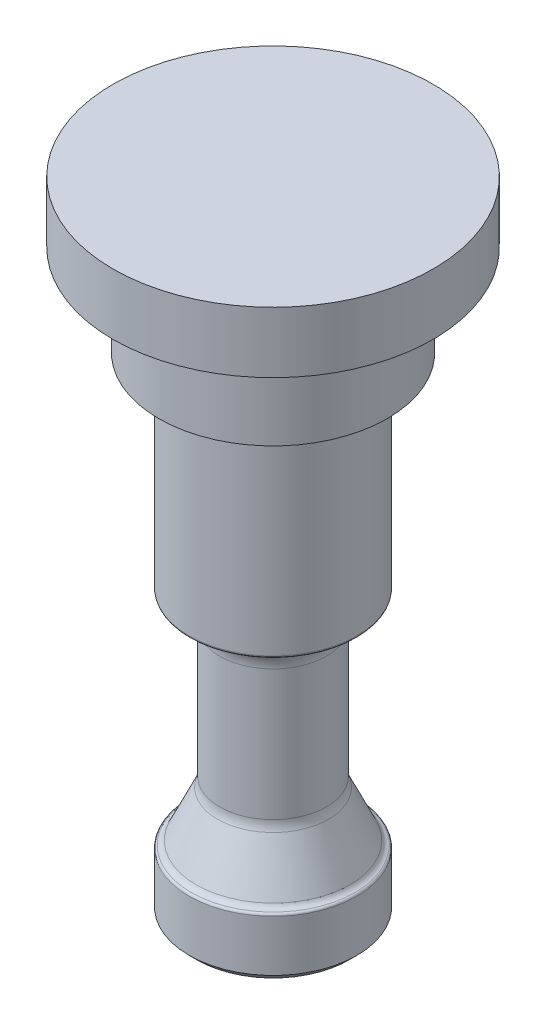
from build123d import *

# Parameters (mm, degrees)
SKETCH1_R               = 8.73125
MAIN_DEPTH              = 50.8
CHAMFER1_SIZE           = 0.79375
FILLET1_R               = 0.254
SKETCH6_R               = 11.90625
SPRING_STABILIZER_DEPTH = 9.525
SKETCH3_R               = 16.66875
TOP_CAP_DEPTH           = 6.35
FILLET2_R               = 1.27
SKETCH7_R               = 2.38125
CUT_EXTRUDE1_DEPTH      = 19.05


with BuildPart() as part:
    # Sketch1 → main (new body)
    with BuildSketch(Plane(origin=(0, 0, 0), x_dir=(1, 0, 0), z_dir=(0, 1, 0))):
        with Locations(Location((0, 0, 0), (0, 0, 270))):
            Circle(SKETCH1_R)
    extrude(amount=MAIN_DEPTH)

    # Chamfer1
    chamfer1_edges = [part.edges().sort_by_distance(p)[0] for p in [
        (0, 0, -8.73125),
    ]]
    chamfer(chamfer1_edges, length=CHAMFER1_SIZE)

    # Sketch2 → ball_channel (revolve, cut)
    with BuildSketch(Plane(origin=(0, 0, 0), x_dir=(0, 0, -1), z_dir=(1, 0, 0))):
        with BuildLine():
            Line((-5.779354582, 11.595937646), (-8.011868194, 6.808296755))
            ThreePointArc((-8.011868194, 6.808296755), (-8.304768436, 6.47430804), (-8.73125, 6.35))
            Line((-8.73125, 6.35), (-8.73125, 29.36875))
            ThreePointArc((-8.73125, 29.36875), (-6.48618597, 28.43881403), (-5.55625, 26.19375))
            Line((-5.55625, 26.19375), (-5.55625, 12.602297381))
            ThreePointArc((-5.55625, 12.602297381), (-5.612695133, 12.086900551), (-5.779354582, 11.595937646))
        make_face()
    revolve(axis=Axis((0, 50.8, 0), (0, -1, 0)), mode=Mode.SUBTRACT)

    # Fillet1
    fillet1_edges = [part.edges().sort_by_distance(p)[0] for p in [
        (0, 6.35, -8.73125),
        (0, 29.36875, -8.73125),
        (0, 50.8, -8.73125),
    ]]
    fillet(fillet1_edges, radius=FILLET1_R)

    # Sketch6 → spring_stabilizer (add)
    with BuildSketch(Plane(origin=(0, 50.8, 0), x_dir=(1, 0, 0), z_dir=(0, 1, 0))):
        with Locations(Location((0, 0, 0), (0, 0, 90))):
            Circle(SKETCH6_R)
    extrude(amount=SPRING_STABILIZER_DEPTH)

    # Sketch3 → top_cap (add)
    with BuildSketch(Plane(origin=(0, 60.325, 0), x_dir=(1, 0, 0), z_dir=(0, 1, 0))):
        with Locations(Location((0, 0, 0), (0, 0, 270))):
            Circle(SKETCH3_R)
    extrude(amount=TOP_CAP_DEPTH)

    # Fillet2
    fillet2_edges = [part.edges().sort_by_distance(p)[0] for p in [
        (0, 60.325, 11.90625),
    ]]
    fillet(fillet2_edges, radius=FILLET2_R)

    # Sketch7 → Cut-Extrude1 (cut)
    with BuildSketch(Plane.XZ):
        with Locations(Location((0, 0, 0), (0, 0, 270))):
            Circle(SKETCH7_R)
    extrude(amount=-CUT_EXTRUDE1_DEPTH, mode=Mode.SUBTRACT)


solid = part.part
